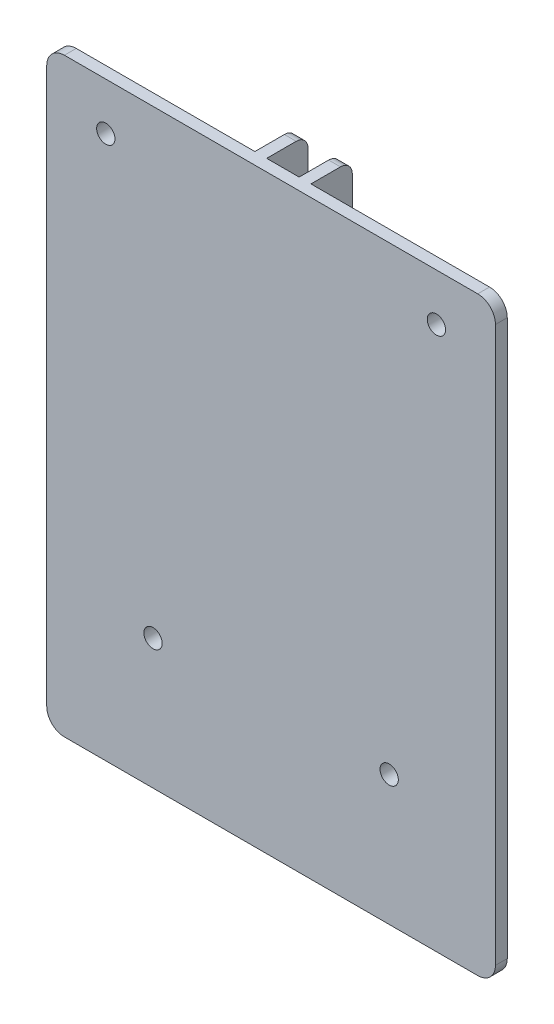
from build123d import *

# Parameters (mm, degrees)
ESQUISSE1_W                  = 76
ESQUISSE1_H                  = 100
BOSS_EXTRU_1_DEPTH           = 9
ESQUISSE2_W                  = 33.25
ESQUISSE2_H                  = 100
ESQUISSE2_W_2                = 5.5
ENL_V_MAT_EXTRU_1_DEPTH      = 7
ESQUISSE3_R                  = 1.55
ENL_V_MAT_EXTRU_2_DEPTH      = 43.75
CONG_1_R                     = 3
CONG_2_R                     = 2
ESQUISSE9_R                  = 3
BOSS_EXTRU_2_DEPTH           = 3
ESQUISSE5_R                  = 1.55
ENL_V_MAT_EXTRU_4_DEPTH      = 8
ENL_V_MAT_EXTRU_4_DEPTH_BACK = 3


with BuildPart() as part:
    # Esquisse1 → Boss.-Extru.1 (new body)
    with BuildSketch(Plane.XY):
        with Locations((38, 50)):
            Rectangle(ESQUISSE1_W, ESQUISSE1_H)
    extrude(amount=BOSS_EXTRU_1_DEPTH)

    # Esquisse2 → Enlèv. mat.-Extru.1 (cut)
    with BuildSketch(Plane(origin=(0, 0, 0), x_dir=(-1, 0, 0), z_dir=(0, 0, -1))):
        with Locations((-16.625, 50)):
            Rectangle(ESQUISSE2_W, ESQUISSE2_H)
        with Locations((-59.375, 50)):
            Rectangle(ESQUISSE2_W, ESQUISSE2_H)
        with Locations((-38, 50)):
            Rectangle(ESQUISSE2_W_2, ESQUISSE2_H)
    extrude(amount=-ENL_V_MAT_EXTRU_1_DEPTH, mode=Mode.SUBTRACT)

    # Esquisse3 → Enlèv. mat.-Extru.2 (cut, through all)
    with BuildSketch(Plane(origin=(42.75, 0, 0), x_dir=(0, 0, -1), z_dir=(1, 0, 0))):
        with Locations((-3.5, 15)):
            Circle(ESQUISSE3_R)
        with Locations((-3.5, 85)):
            Circle(ESQUISSE3_R)
    extrude(amount=-ENL_V_MAT_EXTRU_2_DEPTH, mode=Mode.SUBTRACT)

    # Congé1
    cong_1_edges = [part.edges().sort_by_distance(p)[0] for p in [
        (0, 100, 8),
        (76, 100, 8),
        (76, 0, 8),
        (0, 0, 8),
    ]]
    fillet(cong_1_edges, radius=CONG_1_R)

    # Congé2
    cong_2_edges = [part.edges().sort_by_distance(p)[0] for p in [
        (41.75, 100, 0),
        (34.25, 100, 0),
        (34.25, 0, 0),
        (41.75, 0, 0),
    ]]
    fillet(cong_2_edges, radius=CONG_2_R)

    # Esquisse9 → Boss.-Extru.2 (add)
    with BuildSketch(Plane(origin=(0, 0, 7), x_dir=(-1, 0, 0), z_dir=(0, 0, -1))):
        with Locations((-66, 92)):
            Circle(ESQUISSE9_R)
        with Locations((-10, 92)):
            Circle(ESQUISSE9_R)
        with Locations((-18, 22)):
            Circle(ESQUISSE9_R)
        with Locations((-58, 22)):
            Circle(ESQUISSE9_R)
    extrude(amount=BOSS_EXTRU_2_DEPTH)

    # Esquisse5 → Enlèv. mat.-Extru.4 (cut, two sides)
    with BuildSketch(Plane(origin=(0, 0, 7), x_dir=(-1, 0, 0), z_dir=(0, 0, -1))) as enl_v_mat_extru_4_sk:
        with Locations((-66, 92)):
            Circle(ESQUISSE5_R)
        with Locations((-58, 22)):
            Circle(ESQUISSE5_R)
        with Locations((-18, 22)):
            Circle(ESQUISSE5_R)
        with Locations((-10, 92)):
            Circle(ESQUISSE5_R)
    extrude(amount=ENL_V_MAT_EXTRU_4_DEPTH, mode=Mode.SUBTRACT)
    extrude(enl_v_mat_extru_4_sk.sketch, amount=-ENL_V_MAT_EXTRU_4_DEPTH_BACK, mode=Mode.SUBTRACT)


solid = part.part
